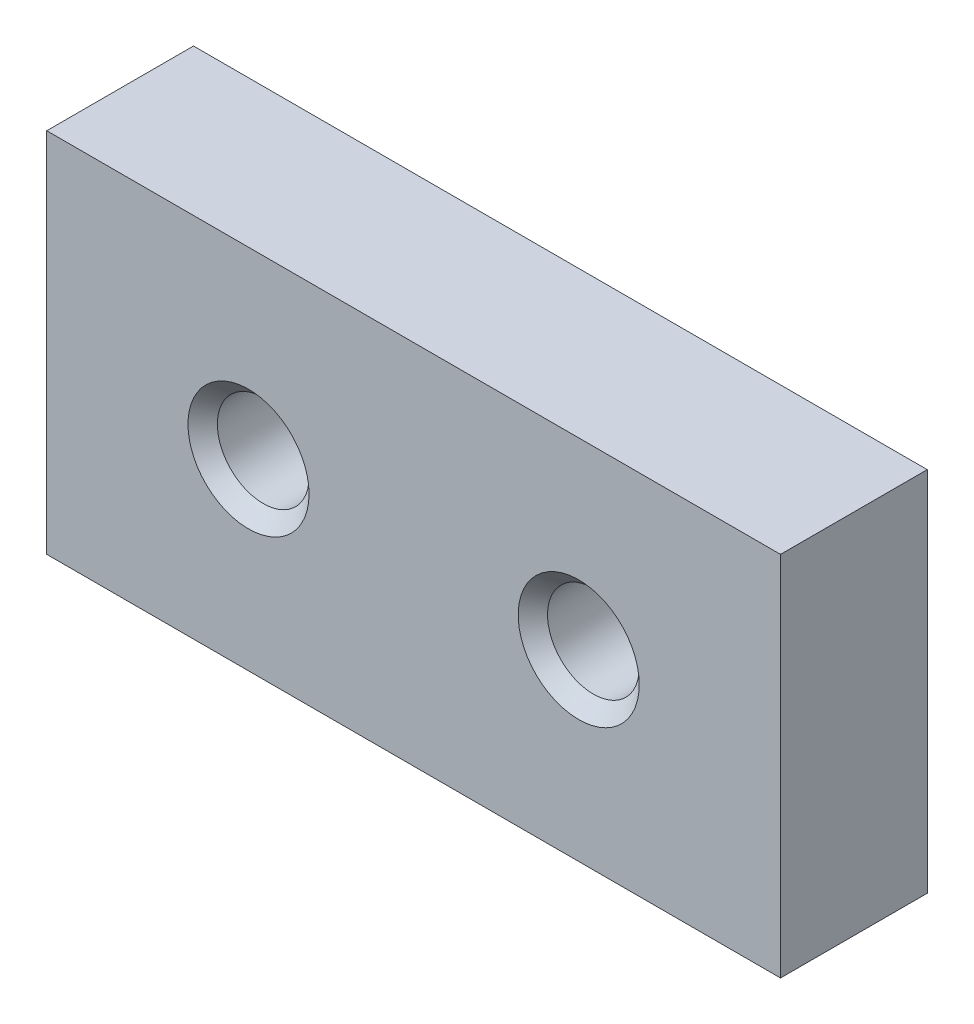
from build123d import *

# Parameters (mm, degrees)
SKETCH_1_W         = 20
SKETCH_1_H         = 10
EXTRUDE_1_DEPTH    = 4
M3X0_51_AT_2_COUNT = 2
M3X0_51_AT_2_PITCH = 9


with BuildPart() as part:
    # Эскиз1 → Бобышка-Вытянуть1 (new body)
    with BuildSketch(Plane.XY):
        Rectangle(SKETCH_1_W, SKETCH_1_H)
    extrude(amount=EXTRUDE_1_DEPTH)

    # Эскиз2 → Отверстие обработанное метчиком M3x0.51 (revolve, cut)
    with BuildSketch(Plane(origin=(-4.5, 0, 4), x_dir=(0, -1, 0), z_dir=(1, 0, 0))):
        Polygon((0, 0), (0, 4), (1.65, 4), (1.25, 3.6), (1.25, 0.4), (1.65, 0), align=None)
    m3x0_51 = revolve(axis=Axis((-4.5, 0, 10.35), (0, 0, -1)), mode=Mode.SUBTRACT)

    # Отверстие обработанное метчиком M3x0.51 at 2: Отверстие обработанное метчиком M3x0.51 ×2
    with Locations(*[(i * M3X0_51_AT_2_PITCH, 0, 0) for i in range(1, M3X0_51_AT_2_COUNT)]):
        add(m3x0_51, mode=Mode.SUBTRACT)


solid = part.part
